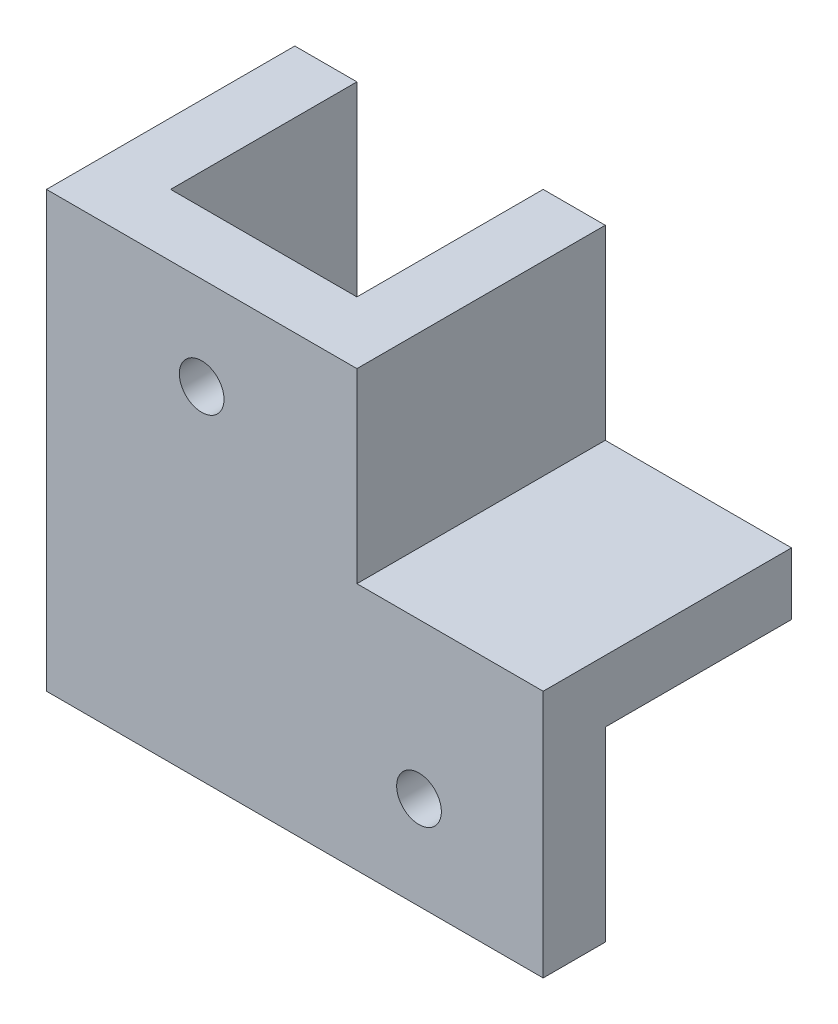
from build123d import *

# Parameters (mm, degrees)
BOSS_EXTRUDE1_DEPTH = 5
BOSS_EXTRUDE2_DEPTH = 15
SKETCH3_W           = 5
SKETCH3_H           = 35
BOSS_EXTRUDE3_DEPTH = 15
SKETCH4_W           = 5
SKETCH4_H           = 35
BOSS_EXTRUDE4_DEPTH = 5
BOSS_EXTRUDE5_DEPTH = 5
SKETCH7_R           = 1.8
CUT_EXTRUDE1_DEPTH  = 6


with BuildPart() as part:
    # Sketch1 → Boss-Extrude1 (new body)
    with BuildSketch(Plane.XY):
        Polygon((-7.529880478, -25.806772908), (27.470119522, -25.806772908), (27.470119522, -10.806772908), (7.470119522, -10.806772908), (7.470119522, 9.193227092), (-7.529880478, 9.193227092), align=None)
    extrude(amount=BOSS_EXTRUDE1_DEPTH)



with BuildPart() as body_2:
    # Sketch2 → Boss-Extrude2 (new body)
    with BuildSketch(Plane(origin=(0, 0, 0), x_dir=(-1, 0, 0), z_dir=(0, 0, -1))):
        Polygon((-7.470119522, 9.193227092), (-12.470119522, 9.193227092), (-12.470119522, -5.806772908), (-27.470119522, -5.806772908), (-27.470119522, -10.806772908), (-7.470119522, -10.806772908), align=None)
    extrude(amount=BOSS_EXTRUDE2_DEPTH)


with BuildPart() as body_3:
    # Sketch3 → Boss-Extrude3 (new body)
    with BuildSketch(Plane(origin=(0, 0, 0), x_dir=(-1, 0, 0), z_dir=(0, 0, -1))):
        with Locations((10.029880478, -8.306772908)):
            Rectangle(SKETCH3_W, SKETCH3_H)
    extrude(amount=BOSS_EXTRUDE3_DEPTH)


with BuildPart() as part_1:
    add(part.part)

    add(body_3.part)  # Boss-Extrude4 merges body 3
    # Sketch4 → Boss-Extrude4 (add)
    with BuildSketch(Plane.XY):
        with Locations((-10.029880478, -8.306772908)):
            Rectangle(SKETCH4_W, SKETCH4_H)
    extrude(amount=BOSS_EXTRUDE4_DEPTH)


    add(body_2.part)  # Boss-Extrude5 merges body 2
    # Sketch5 → Boss-Extrude5 (add)
    with BuildSketch(Plane.XY):
        Polygon((7.470119522, 9.193227092), (7.470119522, -10.806772908), (27.470119522, -10.806772908), (27.470119522, -5.806772908), (12.470119522, -5.806772908), (12.470119522, 9.193227092), align=None)
    extrude(amount=BOSS_EXTRUDE5_DEPTH)

    # Sketch7 → Cut-Extrude1 (cut, through all)
    with BuildSketch(Plane(origin=(0, 0, 0), x_dir=(-1, 0, 0), z_dir=(0, 0, -1))):
        with Locations((0.029880478, 1.693227092)):
            Circle(SKETCH7_R)
        with Locations((-17.470119522, -18.306772908)):
            Circle(SKETCH7_R)
    extrude(amount=-CUT_EXTRUDE1_DEPTH, mode=Mode.SUBTRACT)


solid = part_1.part
